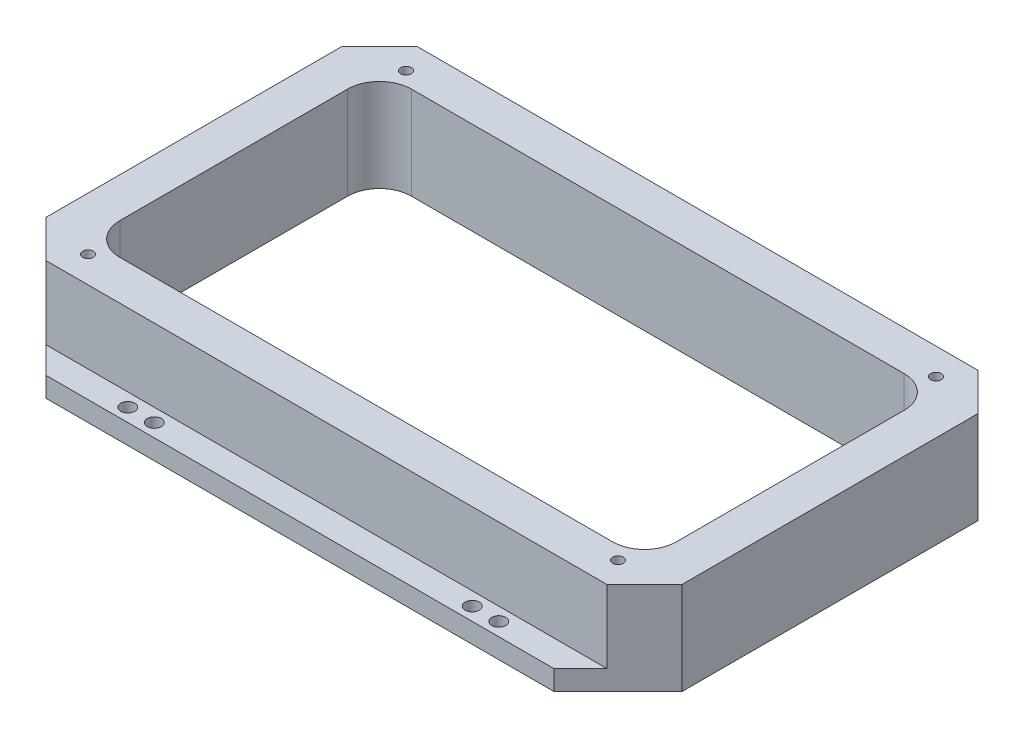
from build123d import *

# Parameters (mm, degrees)
SKETCH1_W                   = 304.8
SKETCH1_H                   = 177.8
BOSS_EXTRUDE1_DEPTH         = 44.45
CHAMFER1_SIZE               = 17.9578
CUT_EXTRUDE1_DEPTH          = 45.45
F_1_4_20_TAPPED_HOLE1_D     = 5.1054
F_1_4_20_TAPPED_HOLE1_DEPTH = 19.05
F_1_4_20_TAPPED_HOLE1_TIP   = 1.533816902
BOSS_EXTRUDE2_DEPTH         = 9.525
F_1_4_CLEARANCE_HOLE1_D     = 6.7564
FILLET2_R                   = 15.24


with BuildPart() as part:
    # Sketch1 → Boss-Extrude1 (new body)
    with BuildSketch(Plane(origin=(0, 0, 0), x_dir=(1, 0, 0), z_dir=(0, 1, 0))):
        Rectangle(SKETCH1_W, SKETCH1_H)
    extrude(amount=BOSS_EXTRUDE1_DEPTH)

    # Chamfer1
    chamfer1_edges = [part.edges().sort_by_distance(p)[0] for p in [
        (-152.4, 22.225, -88.9),
        (152.4, 22.225, -88.9),
        (152.4, 22.225, 88.9),
        (-152.4, 22.225, 88.9),
    ]]
    chamfer(chamfer1_edges, length=CHAMFER1_SIZE)

    # Sketch3 → Cut-Extrude1 (cut, through all)
    with BuildSketch(Plane(origin=(0, 44.45, 0), x_dir=(1, 0, 0), z_dir=(0, 1, 0))):
        Polygon((133.35, 63.051431637), (126.551431637, 69.85), (-126.551431637, 69.85), (-133.35, 63.051431637), (-133.35, -63.051431637), (-126.551431637, -69.85), (126.551431637, -69.85), (133.35, -63.051431637), align=None)
        Polygon((-133.35, 63.051431637), (-126.551431637, 69.85), (-133.35, 69.85), align=None)
        Polygon((133.35, 69.85), (126.551431637, 69.85), (133.35, 63.051431637), align=None)
        Polygon((-126.551431637, -69.85), (-133.35, -63.051431637), (-133.35, -69.85), align=None)
        Polygon((133.35, -69.85), (133.35, -63.051431637), (126.551431637, -69.85), align=None)
    extrude(amount=-CUT_EXTRUDE1_DEPTH, mode=Mode.SUBTRACT)

    # 1/4-20 Tapped Hole1
    with Locations(Plane(origin=(0, 44.45, 0), x_dir=(1, 0, 0), z_dir=(0, 1, 0))):
        with Locations((-127, 76.2), (127, 76.2), (127, -76.2), (-127, -76.2)):
            Hole(F_1_4_20_TAPPED_HOLE1_D / 2, depth=F_1_4_20_TAPPED_HOLE1_DEPTH)
            with Locations((0, 0, -(F_1_4_20_TAPPED_HOLE1_DEPTH + F_1_4_20_TAPPED_HOLE1_TIP / 2))):  # 118° drill point
                Cone(0, F_1_4_20_TAPPED_HOLE1_D / 2, F_1_4_20_TAPPED_HOLE1_TIP, mode=Mode.SUBTRACT)

    # Sketch6 → Boss-Extrude2 (add)
    with BuildSketch(Plane.XZ):
        Polygon((121.7422, 101.6), (134.4422, 88.9), (-134.4422, 88.9), (-121.7422, 101.6), align=None)
    boss_extrude2 = extrude(amount=-BOSS_EXTRUDE2_DEPTH)

    # 1/4 Clearance Hole1 (through all)
    with Locations(Plane(origin=(0, 9.525, 0), x_dir=(1, 0, 0), z_dir=(0, 1, 0))):
        with Locations((-88.9, -95.25), (88.9, -95.25), (-76.2, -95.25), (76.2, -95.25)):
            f_1_4_clearance_hole1 = Hole(F_1_4_CLEARANCE_HOLE1_D / 2)

    # Mirror1: Boss-Extrude2, 1/4 Clearance Hole1 across plane
    add(boss_extrude2.mirror(Plane.XY))
    add(f_1_4_clearance_hole1.mirror(Plane.XY), mode=Mode.SUBTRACT)

    # Fillet2
    fillet2_edges = [part.edges().sort_by_distance(p)[0] for p in [
        (133.35, 22.225, -69.85),
        (133.35, 22.225, 69.85),
        (-133.35, 22.225, 69.85),
        (-133.35, 22.225, -69.85),
    ]]
    fillet(fillet2_edges, radius=FILLET2_R)


solid = part.part
